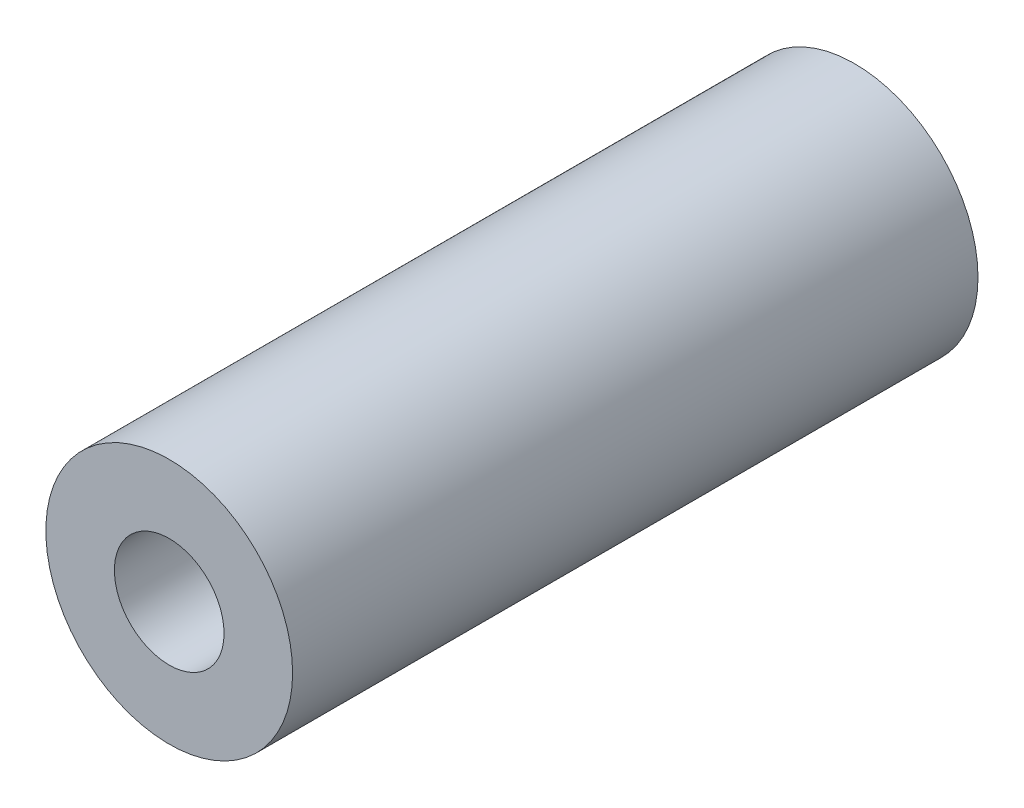
from build123d import *

# Parameters (mm, degrees)
IZIM1_R                     = 18
IZIM1_R_2                   = 8
Y_KSEKLIK_EKSTR_ZYON1_DEPTH = 100


with BuildPart() as part:
    # Çizim1 → Yükseklik-Ekstrüzyon1 (new body)
    with BuildSketch(Plane.XY):
        Circle(IZIM1_R)
        Circle(IZIM1_R_2, mode=Mode.SUBTRACT)
    extrude(amount=Y_KSEKLIK_EKSTR_ZYON1_DEPTH)


solid = part.part
